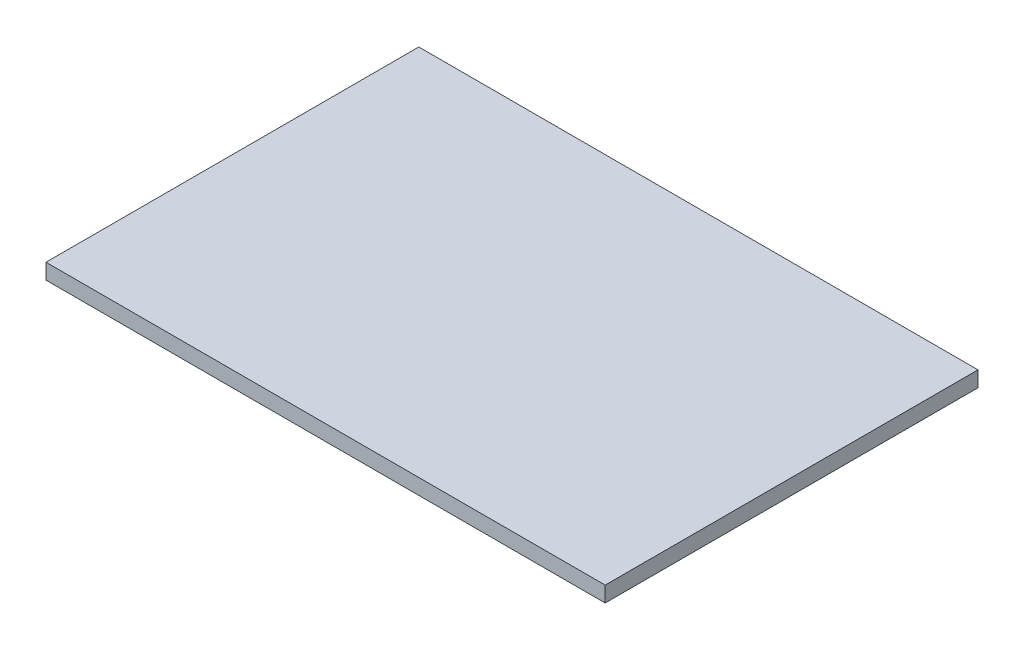
from build123d import *

# Parameters (mm, degrees)
SKETCH_1_W      = 180
SKETCH_1_H      = 120
EXTRUDE_1_DEPTH = 5


with BuildPart() as part:
    # 草图1 → 凸台-拉伸1 (new body)
    with BuildSketch(Plane(origin=(0, 0, 0), x_dir=(1, 0, 0), z_dir=(0, 1, 0))):
        Rectangle(SKETCH_1_W, SKETCH_1_H)
    extrude(amount=EXTRUDE_1_DEPTH)


solid = part.part
